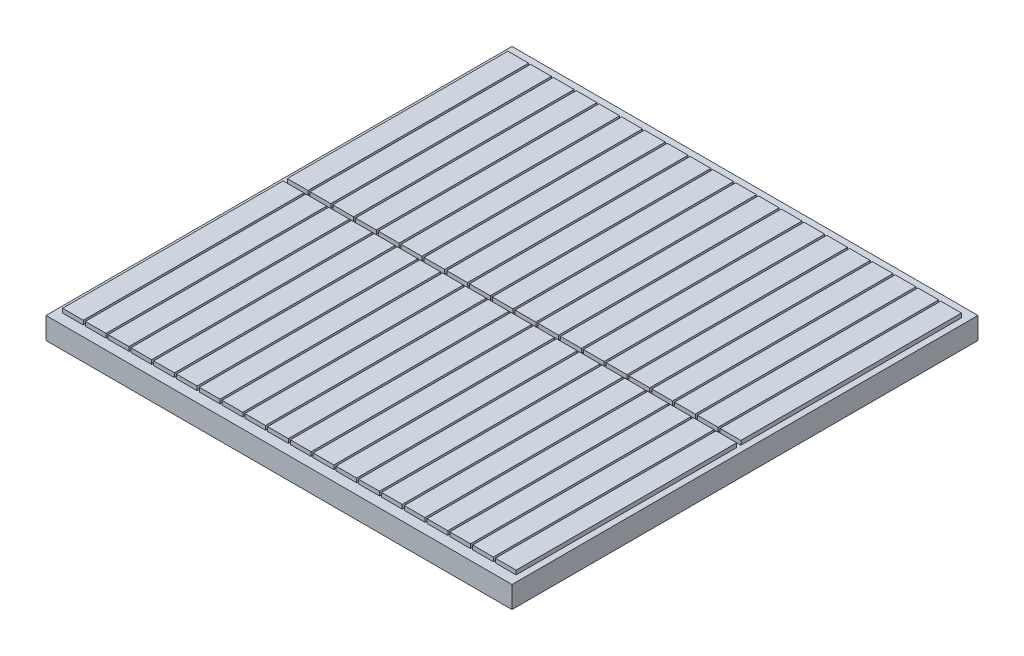
from build123d import *

# Parameters (mm, degrees)
SKETCH1_W           = 45
SKETCH1_H           = 45
BOSS_EXTRUDE1_DEPTH = 0.1
SKETCH2_W           = 45
SKETCH2_H           = 45
BOSS_EXTRUDE2_DEPTH = 2
SKETCH5_W           = 2
SKETCH5_H           = 21.3
BOSS_EXTRUDE3_DEPTH = 0.4


with BuildPart() as part:
    # Sketch1 → Boss-Extrude1 (new body)
    with BuildSketch(Plane(origin=(0, 0, 0), x_dir=(1, 0, 0), z_dir=(0, 1, 0))):
        Rectangle(SKETCH1_W, SKETCH1_H)
    extrude(amount=BOSS_EXTRUDE1_DEPTH)

    # Sketch2 → Boss-Extrude2 (add)
    with BuildSketch(Plane(origin=(0, 0.1, 0), x_dir=(1, 0, 0), z_dir=(0, 1, 0))):
        Rectangle(SKETCH2_W, SKETCH2_H)
    extrude(amount=BOSS_EXTRUDE2_DEPTH)

    # Sketch5 → Boss-Extrude3 (add)
    with BuildSketch(Plane(origin=(0, 2.1, 0), x_dir=(1, 0, 0), z_dir=(0, 1, 0))):
        with Locations((-20.9, 10.85)):
            Rectangle(SKETCH5_W, SKETCH5_H)
        with Locations((-18.7, 10.85)):
            Rectangle(SKETCH5_W, SKETCH5_H)
        with Locations((-16.5, 10.85)):
            Rectangle(SKETCH5_W, SKETCH5_H)
        with Locations((-14.3, 10.85)):
            Rectangle(SKETCH5_W, SKETCH5_H)
        with Locations((-12.1, 10.85)):
            Rectangle(SKETCH5_W, SKETCH5_H)
        with Locations((-9.9, 10.85)):
            Rectangle(SKETCH5_W, SKETCH5_H)
        with Locations((-7.7, 10.85)):
            Rectangle(SKETCH5_W, SKETCH5_H)
        with Locations((-5.5, 10.85)):
            Rectangle(SKETCH5_W, SKETCH5_H)
        with Locations((-3.3, 10.85)):
            Rectangle(SKETCH5_W, SKETCH5_H)
        with Locations((-1.1, 10.85)):
            Rectangle(SKETCH5_W, SKETCH5_H)
        with Locations((1.1, 10.85)):
            Rectangle(SKETCH5_W, SKETCH5_H)
        with Locations((3.3, 10.85)):
            Rectangle(SKETCH5_W, SKETCH5_H)
        with Locations((7.7, 10.85)):
            Rectangle(SKETCH5_W, SKETCH5_H)
        with Locations((9.9, 10.85)):
            Rectangle(SKETCH5_W, SKETCH5_H)
        with Locations((12.1, 10.85)):
            Rectangle(SKETCH5_W, SKETCH5_H)
        with Locations((14.3, 10.85)):
            Rectangle(SKETCH5_W, SKETCH5_H)
        with Locations((16.5, 10.85)):
            Rectangle(SKETCH5_W, SKETCH5_H)
        with Locations((18.7, 10.85)):
            Rectangle(SKETCH5_W, SKETCH5_H)
        with Locations((20.9, 10.85)):
            Rectangle(SKETCH5_W, SKETCH5_H)
        with Locations((20.9, -10.85)):
            Rectangle(SKETCH5_W, SKETCH5_H)
        with Locations((14.3, -10.85)):
            Rectangle(SKETCH5_W, SKETCH5_H)
        with Locations((12.1, -10.85)):
            Rectangle(SKETCH5_W, SKETCH5_H)
        with Locations((9.9, -10.85)):
            Rectangle(SKETCH5_W, SKETCH5_H)
        with Locations((7.7, -10.85)):
            Rectangle(SKETCH5_W, SKETCH5_H)
        with Locations((5.5, -10.85)):
            Rectangle(SKETCH5_W, SKETCH5_H)
        with Locations((1.1, -10.85)):
            Rectangle(SKETCH5_W, SKETCH5_H)
        with Locations((-1.1, -10.85)):
            Rectangle(SKETCH5_W, SKETCH5_H)
        with Locations((-3.3, -10.85)):
            Rectangle(SKETCH5_W, SKETCH5_H)
        with Locations((-5.5, -10.85)):
            Rectangle(SKETCH5_W, SKETCH5_H)
        with Locations((-7.7, -10.85)):
            Rectangle(SKETCH5_W, SKETCH5_H)
        with Locations((-9.9, -10.85)):
            Rectangle(SKETCH5_W, SKETCH5_H)
        with Locations((-12.1, -10.85)):
            Rectangle(SKETCH5_W, SKETCH5_H)
        with Locations((-14.3, -10.85)):
            Rectangle(SKETCH5_W, SKETCH5_H)
        with Locations((-16.5, -10.85)):
            Rectangle(SKETCH5_W, SKETCH5_H)
        with Locations((-18.7, -10.85)):
            Rectangle(SKETCH5_W, SKETCH5_H)
        with Locations((-20.9, -10.85)):
            Rectangle(SKETCH5_W, SKETCH5_H)
        with Locations((5.5, 10.85)):
            Rectangle(SKETCH5_W, SKETCH5_H)
        with Locations((18.7, -10.85)):
            Rectangle(SKETCH5_W, SKETCH5_H)
        with Locations((16.5, -10.85)):
            Rectangle(SKETCH5_W, SKETCH5_H)
        with Locations((3.3, -10.85)):
            Rectangle(SKETCH5_W, SKETCH5_H)
    extrude(amount=BOSS_EXTRUDE3_DEPTH)


solid = part.part
